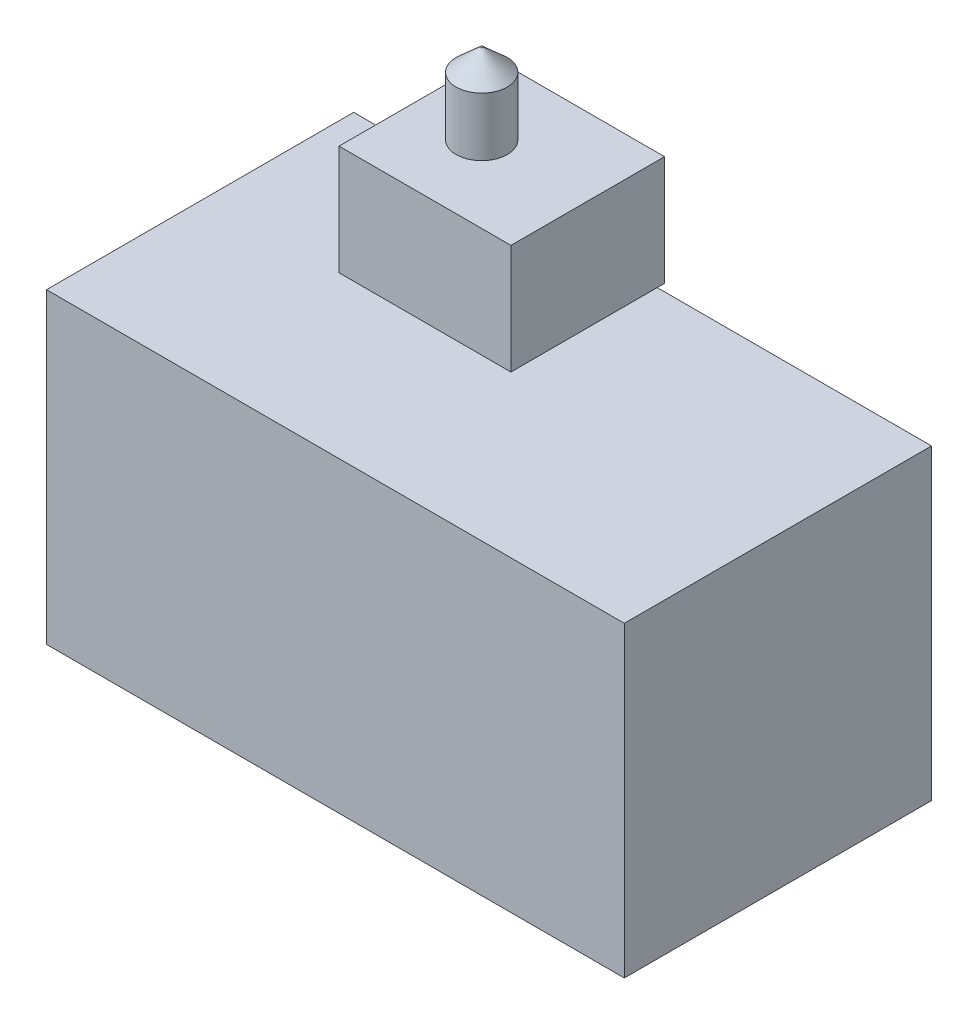
from build123d import *

# Parameters (mm, degrees)
SKETCH1_W           = 79
SKETCH1_H           = 42
BOSS_EXTRUDE1_DEPTH = 42
BOSS_EXTRUDE2_START = 5
SKETCH3_W           = 23.5
SKETCH3_H           = 21
BOSS_EXTRUDE2_DEPTH = 15
SKETCH4_R           = 3.5
BOSS_EXTRUDE3_DEPTH = 8
SKETCH6_R           = 3.5
BOSS_EXTRUDE4_DEPTH = 5


with BuildPart() as part:
    # Sketch1 → Boss-Extrude1 (new body)
    with BuildSketch(Plane.XY):
        with Locations((39.5, 21)):
            Rectangle(SKETCH1_W, SKETCH1_H)
    extrude(amount=BOSS_EXTRUDE1_DEPTH)



with BuildPart() as body_2:
    # Sketch3 → Boss-Extrude2 (new body)
    with BuildSketch(Plane(origin=(0, 42, 0), x_dir=(1, 0, 0), z_dir=(0, 1, 0)).offset(BOSS_EXTRUDE2_START)):
        with Locations((34.75, -14.5)):
            Rectangle(SKETCH3_W, SKETCH3_H)
    extrude(amount=BOSS_EXTRUDE2_DEPTH)


with BuildPart() as body_3:
    # Sketch4 → Boss-Extrude3 (new body)
    with BuildSketch(Plane(origin=(0, 62, 0), x_dir=(1, 0, 0), z_dir=(0, 1, 0))):
        with Locations((32, -14.5)):
            Circle(SKETCH4_R)
    extrude(amount=BOSS_EXTRUDE3_DEPTH)

    # Sketch5 → Revolve1 (revolve)
    with BuildSketch(Plane(origin=(0, 0, 14.5), x_dir=(-1, 0, 0), z_dir=(0, 0, -1))):
        Polygon((-32, 70), (-32, 73), (-31.85, 73), (-28.5, 70), align=None)
    revolve(axis=Axis((32, 70, 14.5), (0, 1, 0)))


with BuildPart() as part_1:
    add(part.part)

    add(body_2.part)  # Boss-Extrude4 merges body 2
    # Sketch6 → Boss-Extrude4 (add)
    with BuildSketch(Plane(origin=(0, 42, 0), x_dir=(1, 0, 0), z_dir=(0, 1, 0))):
        with Locations((32, -14.5)):
            Circle(SKETCH6_R)
    extrude(amount=BOSS_EXTRUDE4_DEPTH)


solid = Compound([body_3.part, part_1.part])
